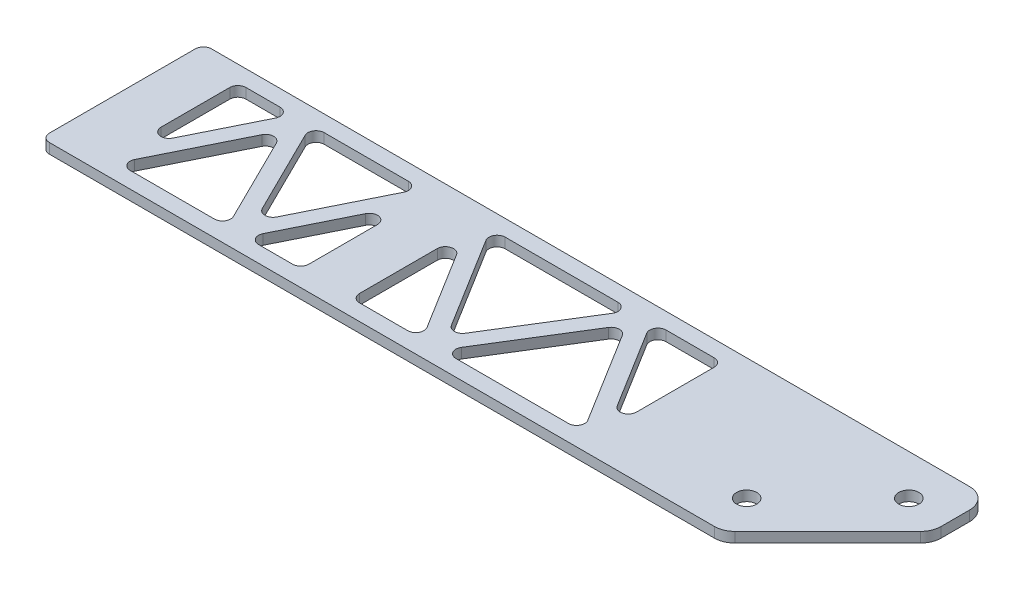
from build123d import *

# Parameters (mm, degrees)
SKETCH1_R           = 3.175
BOSS_EXTRUDE1_DEPTH = 1.5875
FILLET1_R           = 2.54
FILLET2_R           = 6.35


with BuildPart() as part:
    # Sketch1 → Boss-Extrude1 (new body, symmetric)
    with BuildSketch(Plane(origin=(0, 0, 0), x_dir=(1, 0, 0), z_dir=(0, 1, 0))):
        Polygon((121.465512242, -25.4), (154.305, 7.439487758), (154.305, 25.4), (-92.075, 25.4), (-92.075, -25.4), align=None)
        Polygon((-38.817248104, -20.32), (-73.366085229, -20.32), (-56.091666667, 14.592509095), align=None, mode=Mode.SUBTRACT)
        Polygon((-15.875, 14.592509095), (-15.875, -20.32), (-33.149418563, -20.32), align=None, mode=Mode.SUBTRACT)
        Polygon((22.200034711, -20.32), (0, -20.32), (0, 15.498543399), align=None, mode=Mode.SUBTRACT)
        with Locations((116.205, -12.7)):
            Circle(SKETCH1_R, mode=Mode.SUBTRACT)
        Polygon((72.576701378, -20.32), (28.176631956, -20.32), (50.376666667, 15.498543399), align=None, mode=Mode.SUBTRACT)
        Polygon((53.364965289, 20.32), (75.565, 20.32), (75.565, -15.498543399), align=None, mode=Mode.SUBTRACT)
        Polygon((-76.2, -14.592509095), (-76.2, 20.32), (-58.925581437, 20.32), align=None, mode=Mode.SUBTRACT)
        Polygon((-53.257751896, 20.32), (-18.708914771, 20.32), (-35.983333333, -14.592509095), align=None, mode=Mode.SUBTRACT)
        Polygon((2.988298622, 20.32), (47.388368044, 20.32), (25.188333333, -15.498543399), align=None, mode=Mode.SUBTRACT)
        with Locations((141.605, 12.7)):
            Circle(SKETCH1_R, mode=Mode.SUBTRACT)
    extrude(amount=BOSS_EXTRUDE1_DEPTH, both=True)

    # Fillet1
    fillet1_edges = [part.edges().sort_by_distance(p)[0] for p in [
        (-76.2, 0, -20.32),
        (-76.2, 0, 14.592509095),
        (-58.925581437, 0, -20.32),
        (2.988298622, 0, -20.32),
        (25.188333333, 0, 15.498543399),
        (47.388368044, 0, -20.32),
        (0, 0, -15.498543399),
        (0, 0, 20.32),
        (22.200034711, 0, 20.32),
        (72.576701378, 0, 20.32),
        (50.376666667, 0, -15.498543399),
        (28.176631956, 0, 20.32),
        (75.565, 0, 15.498543399),
        (75.565, 0, -20.32),
        (53.364965289, 0, -20.32),
        (-15.875, 0, 20.32),
        (-15.875, 0, -14.592509095),
        (-33.149418563, 0, 20.32),
        (-35.983333333, 0, 14.592509095),
        (-18.708914771, 0, -20.32),
        (-53.257751896, 0, -20.32),
        (-92.075, 0, 25.4),
        (-92.075, 0, -25.4),
        (-38.817248104, 0, 20.32),
        (-56.091666667, 0, -14.592509095),
        (-73.366085229, 0, 20.32),
    ]]
    fillet(fillet1_edges, radius=FILLET1_R)

    # Fillet2
    fillet2_edges = [part.edges().sort_by_distance(p)[0] for p in [
        (154.305, 0, -25.4),
        (154.305, 0, -7.439487758),
        (121.465512242, 0, 25.4),
    ]]
    fillet(fillet2_edges, radius=FILLET2_R)


solid = part.part
